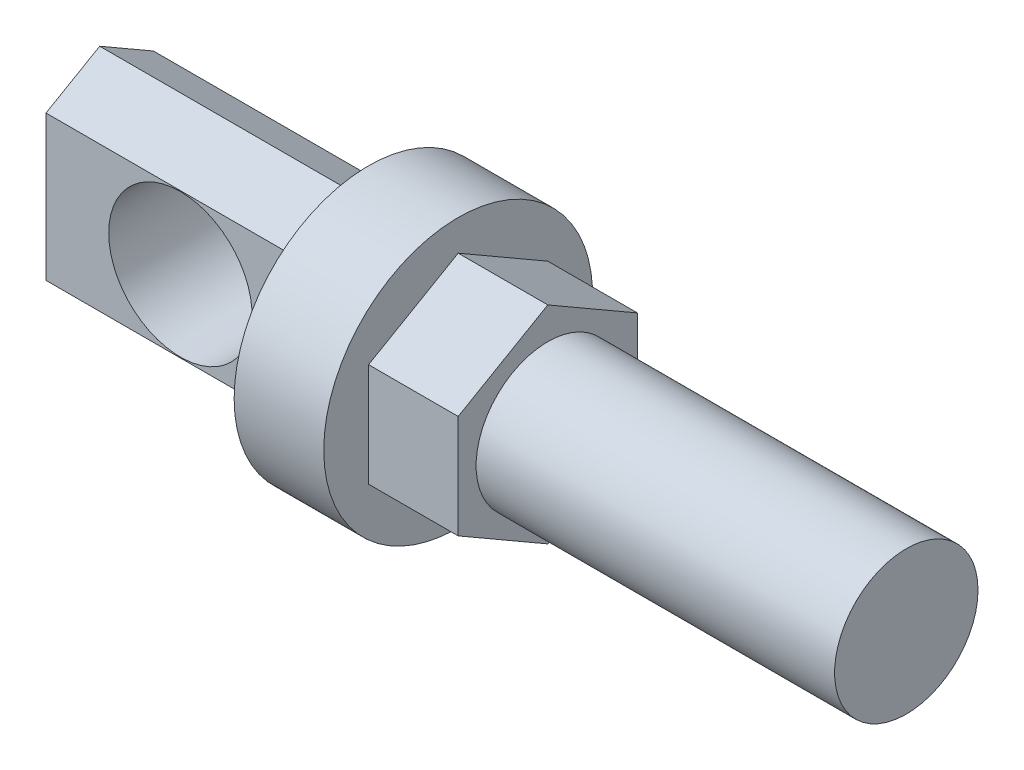
from build123d import *

# Parameters (mm, degrees)
EXTRUDE_1_DEPTH     = 10
SKETCH_2_R          = 8
EXTRUDE_2_DEPTH     = 40
SKETCH_5_R          = 15
EXTRUDE_4_DEPTH     = 10
EXTRUDE_3_DEPTH     = 30
CUT_EXTRUDE_1_REACH = 23.002
SKETCH_4_R          = 8


with BuildPart() as part:
    # Эскиз1 → Бобышка-Вытянуть1 (new body)
    with BuildSketch(Plane(origin=(0, 0, 0), x_dir=(0, 0, -1), z_dir=(1, 0, 0))):
        Polygon((0, 11.547005384), (-10, 5.773502692), (-10, -5.773502692), (0, -11.547005384), (10, -5.773502692), (10, 5.773502692), align=None)
    extrude(amount=EXTRUDE_1_DEPTH)

    # Эскиз2 → Бобышка-Вытянуть2 (add)
    with BuildSketch(Plane(origin=(10, 0, 0), x_dir=(0, 0, -1), z_dir=(1, 0, 0))):
        Circle(SKETCH_2_R)
    extrude(amount=EXTRUDE_2_DEPTH)

    # Эскиз5 → Бобышка-Вытянуть4 (add)
    with BuildSketch(Plane.ZY):
        Circle(SKETCH_5_R)
    extrude(amount=EXTRUDE_4_DEPTH)

    # Эскиз3 → Бобышка-Вытянуть3 (add)
    with BuildSketch(Plane.ZY.offset(10)):
        Polygon((0, 11.547005384), (-6.001748602, 8.081894213), (-6.001748602, -8.081894213), (0, -11.547005384), (5.991634546, -8.087733566), (5.991634546, 8.087733566), align=None)
    extrude(amount=EXTRUDE_3_DEPTH)

    # Эскиз4 → Вырез-Вытянуть1 (cut, up to next)
    with BuildSketch(Plane(origin=(0, 0, -6.001748602), x_dir=(-1, 0, 0), z_dir=(0, 0, -1)), mode=Mode.PRIVATE) as cut_extrude_1_sk1:
        with Locations((25, 0)):
            Circle(SKETCH_4_R)
    cut_extrude_1_tool1 = extrude(cut_extrude_1_sk1.sketch, amount=-CUT_EXTRUDE_1_REACH, mode=Mode.PRIVATE) & part.part
    add(cut_extrude_1_tool1.solids().sort_by_distance((-25, 0, -6.001749))[0], mode=Mode.SUBTRACT)


solid = part.part
